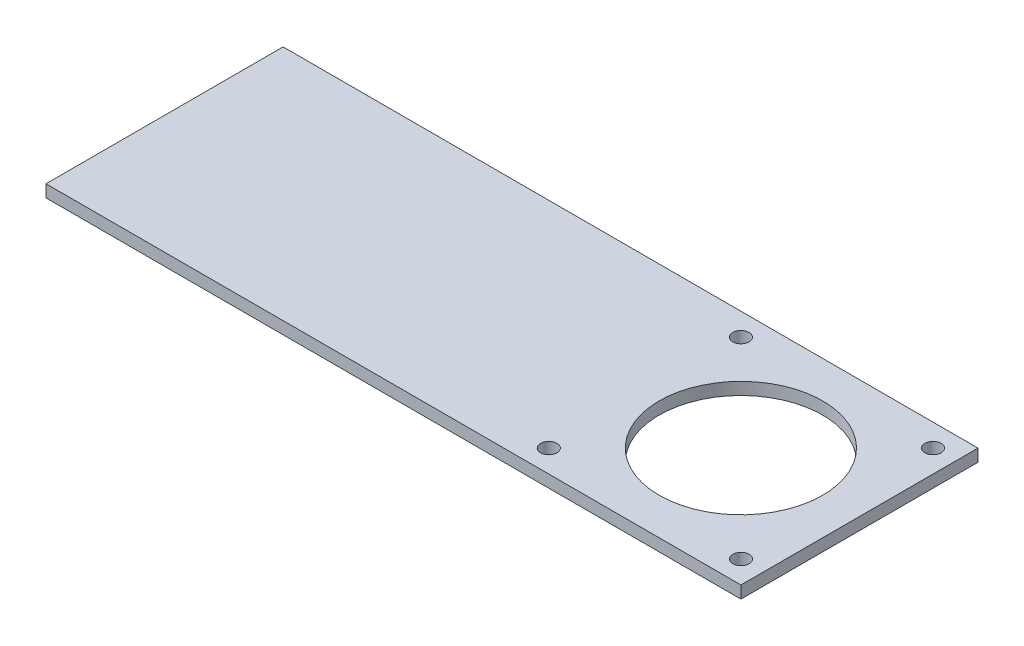
from build123d import *

# Parameters (mm, degrees)
SKETCH1_W           = 170
SKETCH1_H           = 3
BOSS_EXTRUDE1_DEPTH = 58
SKETCH2_R           = 2
SKETCH2_R_2         = 20
CUT_EXTRUDE1_DEPTH  = 58


with BuildPart() as part:
    # Sketch1 → Boss-Extrude1 (new body)
    with BuildSketch(Plane.XY):
        with Locations((-6.063612364, -1.5)):
            Rectangle(SKETCH1_W, SKETCH1_H)
    extrude(amount=BOSS_EXTRUDE1_DEPTH)

    # Sketch2 → Cut-Extrude1 (cut)
    with BuildSketch(Plane(origin=(0, 0, 0), x_dir=(1, 0, 0), z_dir=(0, 1, 0))):
        with Locations((73.436387636, -5.5)):
            Circle(SKETCH2_R)
        with Locations((73.436387636, -52.5)):
            Circle(SKETCH2_R)
        with Locations((26.436387636, -52.5)):
            Circle(SKETCH2_R)
        with Locations((26.436387636, -5.5)):
            Circle(SKETCH2_R)
        with Locations((49.936387636, -29)):
            Circle(SKETCH2_R_2)
    extrude(amount=-CUT_EXTRUDE1_DEPTH, mode=Mode.SUBTRACT)


solid = part.part
